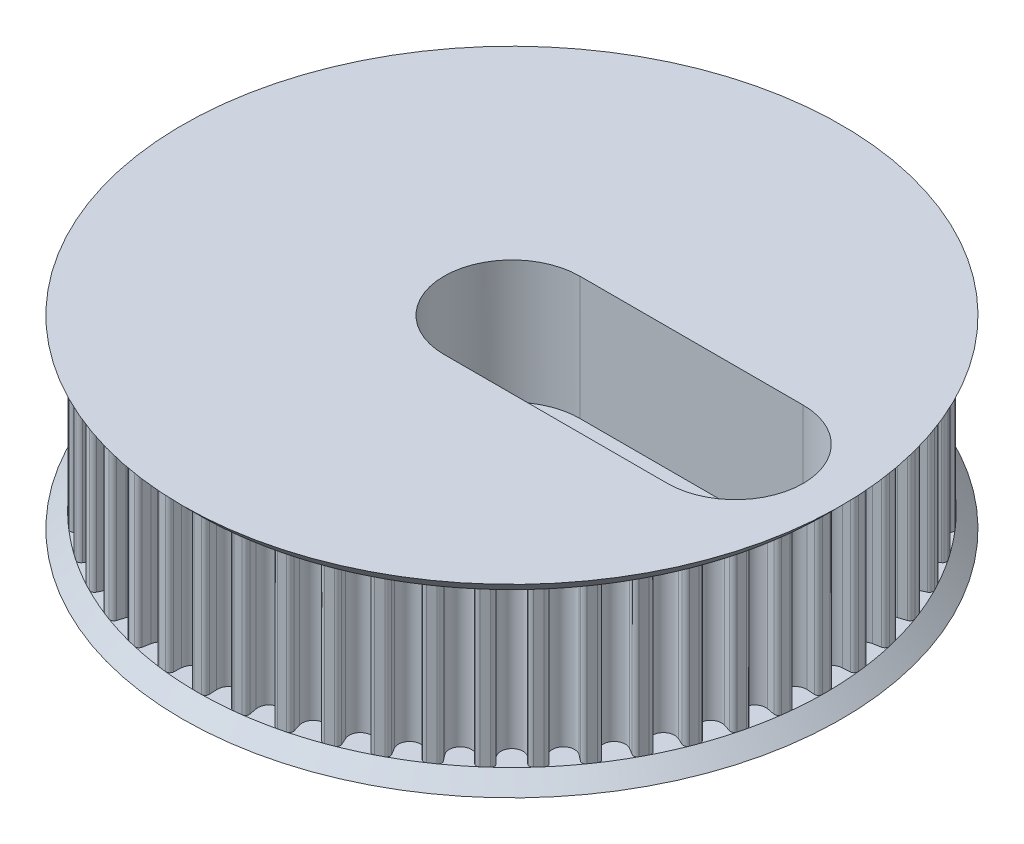
from build123d import *

# Parameters (mm, degrees)
SKETCH5_R                = 40.780285204
BOSS_EXTRUDE1_DEPTH      = 10
CUT_EXTRUDE1_DEPTH       = 59.532583427
FILLET1_R                = 0.5
CIRPATTERN1_COUNT        = 52
FILLET1_OF_CIRPATTERN1_R = 0.5
CUT_EXTRUDE2_DEPTH       = 62.679053205
CUT_EXTRUDE2_DEPTH_BACK  = 62.679053205
SKETCH8_R                = 5
SKETCH8_R_2              = 1.55
CUT_EXTRUDE3_DEPTH       = 16


with BuildPart() as part:
    # Sketch5 → Boss-Extrude1 (new, symmetric)
    with BuildSketch(Plane(origin=(0, 0, 0), x_dir=(1, 0, 0), z_dir=(0, 1, 0))):
        Circle(SKETCH5_R)
    extrude(amount=BOSS_EXTRUDE1_DEPTH, both=True)

    # Sketch5_3 → Cut-Extrude1 (cut, symmetric)
    with BuildSketch(Plane(origin=(0, 0, 0), x_dir=(1, 0, 0), z_dir=(0, 1, 0))):
        with BuildLine():
            ThreePointArc((-1.013340839, 40.767693112), (-2.462252345, 40.705883785), (-3.908049946, 40.592595469))
            Line((-3.908049946, 40.592595469), (-3.816020228, 39.071162854))
            ThreePointArc((-3.816020228, 39.071162854), (-2.281116853, 37.711357122), (-0.92131112, 39.246260497))
            Line((-0.92131112, 39.246260497), (-1.013340839, 40.767693112))
        make_face()
    cut_extrude1 = extrude(amount=CUT_EXTRUDE1_DEPTH, both=True, mode=Mode.SUBTRACT)

    # Fillet1
    fillet1_edges = [part.edges().sort_by_distance(p)[0] for p in [
        (-3.908049946, 0, -40.592595469),
        (-1.013340839, 0, -40.767693112),
    ]]
    fillet(fillet1_edges, radius=FILLET1_R)

    # CirPattern1: Cut-Extrude1 ×52 about axis
    cirpattern1_axis = Axis((0, 36.971387876, 0), (0, -1, 0))
    for i in range(1, CIRPATTERN1_COUNT):
        add(cut_extrude1.rotate(cirpattern1_axis, i * 360 / CIRPATTERN1_COUNT), mode=Mode.SUBTRACT)

    # Fillet1 of CirPattern1
    fillet1_of_cirpattern1_edges = [part.edges().sort_by_distance(p)[0] for p in [
        (1.013340839, 0, -40.767693112),
        (3.908049946, 0, -40.592595469),
        (5.919954833, 0, -40.348305988),
        (8.772452563, 0, -39.825566378),
        (10.740242554, 0, -39.340549706),
        (13.508933067, 0, -38.47779085),
        (15.403913355, 0, -37.759119623),
        (18.048422908, 0, -36.568922487),
        (19.842960412, 0, -35.627076549),
        (22.324726101, 0, -34.126796888),
        (23.992652423, 0, -32.975510474),
        (26.275484517, 0, -31.187025743),
        (27.792477536, 0, -29.843087202),
        (29.843087202, 0, -27.792477536),
        (31.187025743, 0, -26.275484517),
        (32.975510474, 0, -23.992652423),
        (34.126796888, 0, -22.324726101),
        (35.627076549, 0, -19.842960412),
        (36.568922487, 0, -18.048422908),
        (37.759119623, 0, -15.403913355),
        (38.47779085, 0, -13.508933067),
        (39.340549706, 0, -10.740242554),
        (39.825566378, 0, -8.772452563),
        (40.348305988, 0, -5.919954833),
        (40.592595469, 0, -3.908049946),
        (40.767693112, 0, -1.013340839),
        (40.767693112, 0, 1.013340839),
        (40.592595469, 0, 3.908049946),
        (40.348305988, 0, 5.919954833),
        (39.825566378, 0, 8.772452563),
        (39.340549706, 0, 10.740242554),
        (38.47779085, 0, 13.508933067),
        (37.759119623, 0, 15.403913355),
        (36.568922487, 0, 18.048422908),
        (35.627076549, 0, 19.842960412),
        (34.126796888, 0, 22.324726101),
        (32.975510474, 0, 23.992652423),
        (31.187025743, 0, 26.275484517),
        (29.843087202, 0, 27.792477536),
        (27.792477536, 0, 29.843087202),
        (26.275484517, 0, 31.187025743),
        (23.992652423, 0, 32.975510474),
        (22.324726101, 0, 34.126796888),
        (19.842960412, 0, 35.627076549),
        (18.048422908, 0, 36.568922487),
        (15.403913355, 0, 37.759119623),
        (13.508933067, 0, 38.47779085),
        (10.740242554, 0, 39.340549706),
        (8.772452563, 0, 39.825566378),
        (5.919954833, 0, 40.348305988),
        (3.908049946, 0, 40.592595469),
        (1.013340839, 0, 40.767693112),
        (-1.013340839, 0, 40.767693112),
        (-3.908049946, 0, 40.592595469),
        (-5.919954833, 0, 40.348305988),
        (-8.772452563, 0, 39.825566378),
        (-10.740242554, 0, 39.340549706),
        (-13.508933067, 0, 38.47779085),
        (-15.403913355, 0, 37.759119623),
        (-18.048422908, 0, 36.568922487),
        (-19.842960412, 0, 35.627076549),
        (-22.324726101, 0, 34.126796888),
        (-23.992652423, 0, 32.975510474),
        (-26.275484517, 0, 31.187025743),
        (-27.792477536, 0, 29.843087202),
        (-29.843087202, 0, 27.792477536),
        (-31.187025743, 0, 26.275484517),
        (-32.975510474, 0, 23.992652423),
        (-34.126796888, 0, 22.324726101),
        (-35.627076549, 0, 19.842960412),
        (-36.568922487, 0, 18.048422908),
        (-37.759119623, 0, 15.403913355),
        (-38.47779085, 0, 13.508933067),
        (-39.340549706, 0, 10.740242554),
        (-39.825566378, 0, 8.772452563),
        (-40.348305988, 0, 5.919954833),
        (-40.592595469, 0, 3.908049946),
        (-40.767693112, 0, 1.013340839),
        (-40.767693112, 0, -1.013340839),
        (-40.592595469, 0, -3.908049946),
        (-40.348305988, 0, -5.919954833),
        (-39.825566378, 0, -8.772452563),
        (-39.340549706, 0, -10.740242554),
        (-38.47779085, 0, -13.508933067),
        (-37.759119623, 0, -15.403913355),
        (-36.568922487, 0, -18.048422908),
        (-35.627076549, 0, -19.842960412),
        (-34.126796888, 0, -22.324726101),
        (-32.975510474, 0, -23.992652423),
        (-31.187025743, 0, -26.275484517),
        (-29.843087202, 0, -27.792477536),
        (-27.792477536, 0, -29.843087202),
        (-26.275484517, 0, -31.187025743),
        (-23.992652423, 0, -32.975510474),
        (-22.324726101, 0, -34.126796888),
        (-19.842960412, 0, -35.627076549),
        (-18.048422908, 0, -36.568922487),
        (-15.403913355, 0, -37.759119623),
        (-13.508933067, 0, -38.47779085),
        (-10.740242554, 0, -39.340549706),
        (-8.772452563, 0, -39.825566378),
        (-5.919954833, 0, -40.348305988),
    ]]
    fillet(fillet1_of_cirpattern1_edges, radius=FILLET1_OF_CIRPATTERN1_R)

    # Sketch7 → Revolve1 (revolve)
    with BuildSketch(Plane.XY):
        Polygon((0, 12), (0, 10), (40.780285204, 10), (42.780285204, 12), align=None)
    revolve1 = revolve(axis=Axis((0, 36.971387876, 0), (0, -1, 0)))

    # Mirror1: Revolve1 across plane
    add(revolve1.mirror(Plane.ZX))

    # Sketch8 → Cut-Extrude2 (cut, two sides: drawn at the far end of the back side and taken through both)
    with BuildSketch(Plane(origin=(0, 0, 0), x_dir=(1, 0, 0), z_dir=(0, 1, 0)).offset(-CUT_EXTRUDE2_DEPTH_BACK)):
        Circle(SKETCH8_R)
        with Locations((5.126524164, 5.126524164)):
            Circle(SKETCH8_R_2)
        with Locations((5.126524164, -5.126524164)):
            Circle(SKETCH8_R_2)
        with Locations((-5.126524164, -5.126524164)):
            Circle(SKETCH8_R_2)
        with Locations((-5.126524164, 5.126524164)):
            Circle(SKETCH8_R_2)
    extrude(amount=CUT_EXTRUDE2_DEPTH + CUT_EXTRUDE2_DEPTH_BACK, mode=Mode.SUBTRACT)

    # Sketch9 → Cut-Extrude3 (cut)
    with BuildSketch(Plane(origin=(0, 12, 0), x_dir=(1, 0, 0), z_dir=(0, 1, 0))):
        with BuildLine():
            Line((0, 8.808399761), (29, 8.808399761))
            ThreePointArc((29, 8.808399761), (37.808399761, 0), (29, -8.808399761))
            Line((29, -8.808399761), (0, -8.808399761))
            ThreePointArc((0, -8.808399761), (-8.808399761, 0), (0, 8.808399761))
        make_face()
    extrude(amount=-CUT_EXTRUDE3_DEPTH, mode=Mode.SUBTRACT)


solid = part.part
